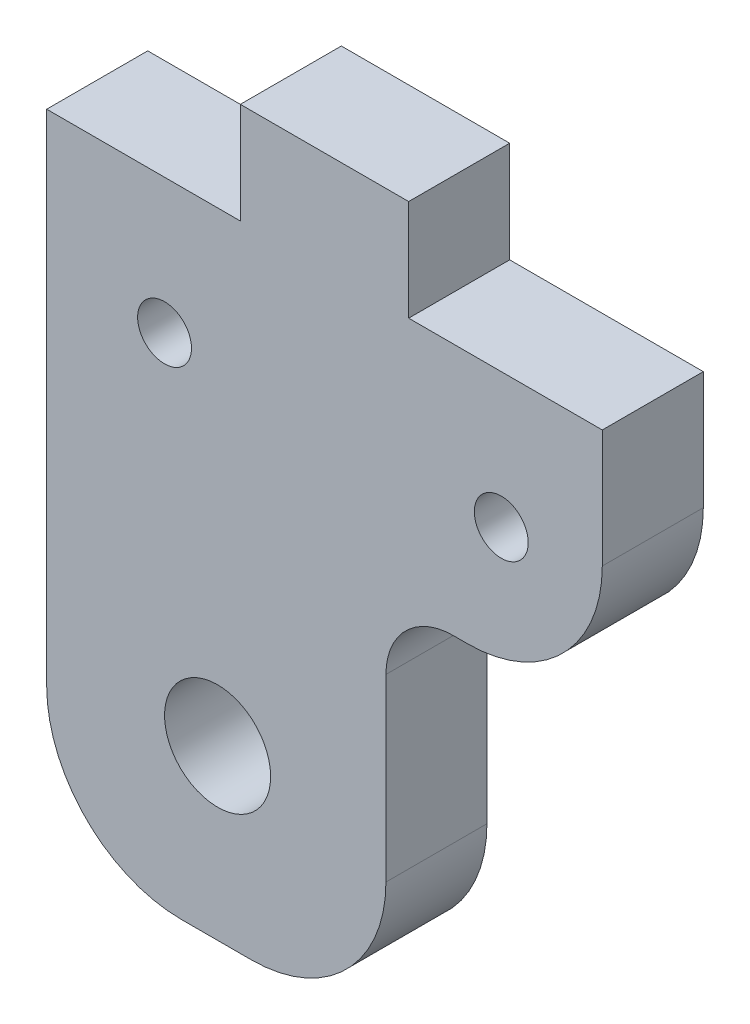
from build123d import *

# Parameters (mm, degrees)
ESBO_O1_R                = 3.15
ESBO_O1_R_2              = 1.6
RESSALTO_EXTRUS_O1_DEPTH = 6
FILETE3_R                = 4
ESBO_O2_W                = 20.15
ESBO_O2_H                = 7.319150415
CORTE_EXTRUS_O1_DEPTH    = 10
FILETE2_R                = 8


with BuildPart() as part:
    # Esboço1 → Ressalto-extrusão1 (new body)
    with BuildSketch(Plane.XY):
        Polygon((20.5, 0), (9, 0), (9, -19), (0, -19), (0, -29), (6, -29), (6, -39), (0, -39), (0, -45), (29.15, -45), (29.15, -15), (42, -15), (42, 0), (30.5, 0), (30.5, 6), (20.5, 6), align=None)
        with Locations((19.15, -27.680849585)):
            Circle(ESBO_O1_R, mode=Mode.SUBTRACT)
        with Locations((16, -8)):
            Circle(ESBO_O1_R_2, mode=Mode.SUBTRACT)
        with Locations((36, -8)):
            Circle(ESBO_O1_R_2, mode=Mode.SUBTRACT)
    extrude(amount=RESSALTO_EXTRUS_O1_DEPTH)

    # Filete3
    filete3_edges = [part.edges().sort_by_distance(p)[0] for p in [
        (29.15, -15, 3),
    ]]
    fillet(filete3_edges, radius=FILETE3_R)

    # Esboço2 → Corte-extrusão1 (cut)
    with BuildSketch(Plane.XY.offset(6)):
        Polygon((9, -19), (0, -19), (0, -29), (6, -29), (6, -39), (0, -39), (0, -45), (9, -45), (9, -37.680849585), align=None)
        with Locations((19.075, -41.340424793)):
            Rectangle(ESBO_O2_W, ESBO_O2_H)
    extrude(amount=-CORTE_EXTRUS_O1_DEPTH, mode=Mode.SUBTRACT)

    # Filete2
    filete2_edges = [part.edges().sort_by_distance(p)[0] for p in [
        (42, -15, 3),
        (9, -37.680849585, 3),
        (29.15, -37.680849585, 3),
    ]]
    fillet(filete2_edges, radius=FILETE2_R)


solid = part.part
